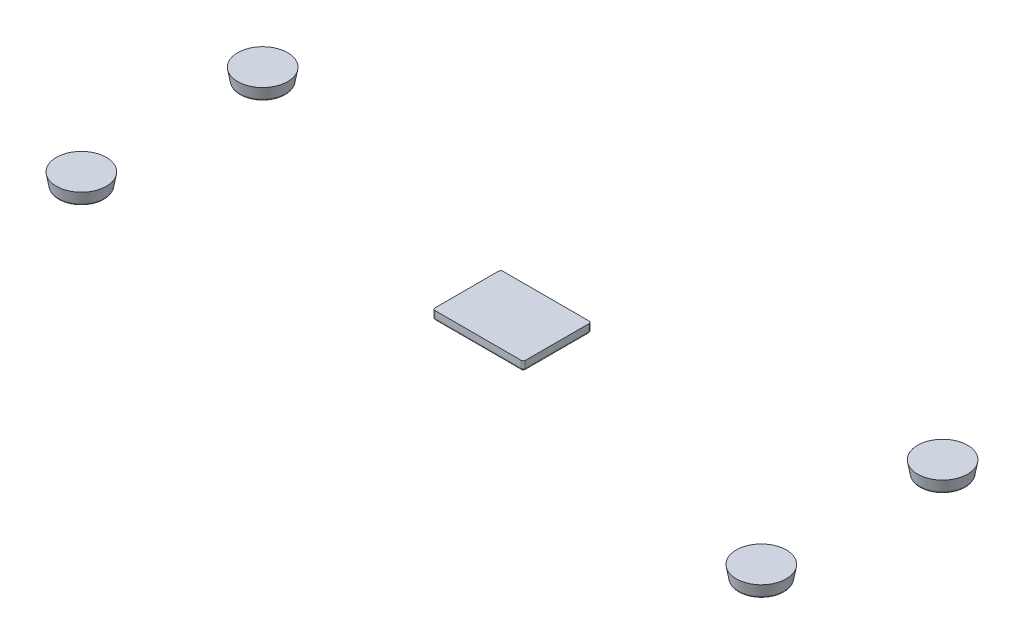
from build123d import *

# Parameters (mm, degrees)
SKETCH1_R             = 5
BOSS_EXTRUDE1_DEPTH   = 2.95
BOSS_EXTRUDE1_TAPER   = -10
BOSS_EXTRUDE1_2_DEPTH = 2.95
BOSS_EXTRUDE1_2_TAPER = -10
BOSS_EXTRUDE1_3_DEPTH = 2.95
BOSS_EXTRUDE1_3_TAPER = -10
BOSS_EXTRUDE1_4_DEPTH = 2.95
BOSS_EXTRUDE1_4_TAPER = -10
FILLET1_R             = 0.5
FILLET2_R             = 0.5
FILLET3_R             = 0.5
FILLET4_R             = 0.5
SKETCH2_W             = 20
SKETCH2_H             = 15
BOSS_EXTRUDE2_DEPTH   = 2
FILLET5_R             = 0.5
FILLET6_R             = 0.5


with BuildPart() as part:
    # Sketch1 → Boss-Extrude1 (new body)
    with BuildSketch(Plane(origin=(0, 0, 0), x_dir=(1, 0, 0), z_dir=(0, 1, 0))):
        with Locations((-75, 20)):
            Circle(SKETCH1_R)
    extrude(amount=BOSS_EXTRUDE1_DEPTH, taper=BOSS_EXTRUDE1_TAPER)

    # Fillet1
    fillet1_edges = [part.edges().sort_by_distance(p)[0] for p in [
        (-80, 0, -20),
    ]]
    fillet(fillet1_edges, radius=FILLET1_R)


with BuildPart() as body_2:
    # Sketch1 → Boss-Extrude1 2 (new body)
    with BuildSketch(Plane(origin=(0, 0, 0), x_dir=(1, 0, 0), z_dir=(0, 1, 0))):
        with Locations((-75, -20)):
            Circle(SKETCH1_R)
    extrude(amount=BOSS_EXTRUDE1_2_DEPTH, taper=BOSS_EXTRUDE1_2_TAPER)

    # Fillet2
    fillet2_edges = [body_2.edges().sort_by_distance(p)[0] for p in [
        (-80, 0, 20),
    ]]
    fillet(fillet2_edges, radius=FILLET2_R)


with BuildPart() as body_3:
    # Sketch1 → Boss-Extrude1 3 (new body)
    with BuildSketch(Plane(origin=(0, 0, 0), x_dir=(1, 0, 0), z_dir=(0, 1, 0))):
        with Locations((75, 20)):
            Circle(SKETCH1_R)
    extrude(amount=BOSS_EXTRUDE1_3_DEPTH, taper=BOSS_EXTRUDE1_3_TAPER)

    # Fillet3
    fillet3_edges = [body_3.edges().sort_by_distance(p)[0] for p in [
        (70, 0, -20),
    ]]
    fillet(fillet3_edges, radius=FILLET3_R)


with BuildPart() as body_4:
    # Sketch1 → Boss-Extrude1 4 (new body)
    with BuildSketch(Plane(origin=(0, 0, 0), x_dir=(1, 0, 0), z_dir=(0, 1, 0))):
        with Locations((75, -20)):
            Circle(SKETCH1_R)
    extrude(amount=BOSS_EXTRUDE1_4_DEPTH, taper=BOSS_EXTRUDE1_4_TAPER)

    # Fillet4
    fillet4_edges = [body_4.edges().sort_by_distance(p)[0] for p in [
        (70, 0, 20),
    ]]
    fillet(fillet4_edges, radius=FILLET4_R)


with BuildPart() as body_5:
    # Sketch2 → Boss-Extrude2 (new body)
    with BuildSketch(Plane(origin=(0, 2.95, 0), x_dir=(1, 0, 0), z_dir=(0, 1, 0))):
        Rectangle(SKETCH2_W, SKETCH2_H)
    extrude(amount=-BOSS_EXTRUDE2_DEPTH)

    # Fillet5
    fillet5_edges = [body_5.edges().sort_by_distance(p)[0] for p in [
        (10, 1.95, 7.5),
        (-10, 1.95, 7.5),
        (-10, 1.95, -7.5),
        (10, 1.95, -7.5),
    ]]
    fillet(fillet5_edges, radius=FILLET5_R)

    # Fillet6
    fillet6_edges = [body_5.edges().sort_by_distance(p)[0] for p in [
        (0, 0.95, -7.5),
        (-10, 0.95, 0),
        (10, 0.95, 0),
        (0, 0.95, 7.5),
        (9.853553391, 0.95, -7.353553391),
        (9.853553391, 0.95, 7.353553391),
        (-9.853553391, 0.95, 7.353553391),
        (-9.853553391, 0.95, -7.353553391),
    ]]
    fillet(fillet6_edges, radius=FILLET6_R)


solid = Compound([part.part, body_2.part, body_3.part, body_4.part, body_5.part])
